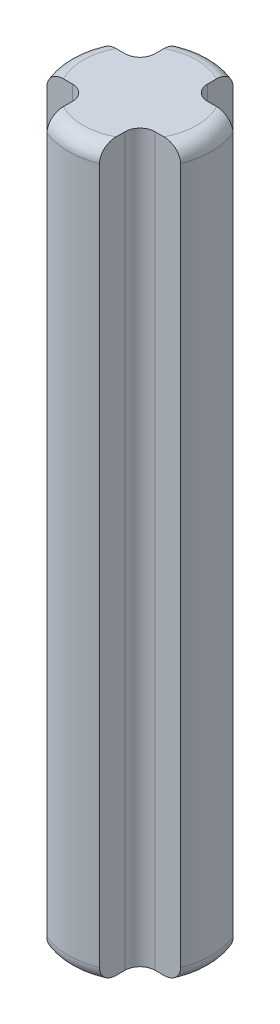
from build123d import *

# Parameters (mm, degrees)
SKETCH1_W          = 2.39
SKETCH1_H          = 24.195
CUT_EXTRUDE1_DEPTH = 25.195
CUT_EXTRUDE2_DEPTH = 25.195
CUT_EXTRUDE3_DEPTH = 25.195
CUT_EXTRUDE4_DEPTH = 25.195
FILLET1_R          = 0.5


with BuildPart() as part:
    # Sketch1 → Revolve1 (revolve)
    with BuildSketch(Plane(origin=(0, 0, 0), x_dir=(-1, 0, 0), z_dir=(0, 0, -1))):
        with Locations((-1.195, 12.0975)):
            Rectangle(SKETCH1_W, SKETCH1_H)
    revolve(axis=Axis((0, 0, 0), (0, 1, 0)))

    # Sketch2 → Cut-Extrude1 (cut, through all)
    with BuildSketch(Plane.XZ):
        with BuildLine():
            Line((0.875, 2.22406722), (0.875, 0.875))
            Line((0.875, 0.875), (2.22406722, 0.875))
            ThreePointArc((2.22406722, 0.875), (1.689985207, 1.689985207), (0.875, 2.22406722))
        make_face()
    extrude(amount=-CUT_EXTRUDE1_DEPTH, mode=Mode.SUBTRACT)

    # Sketch3 → Cut-Extrude2 (cut, through all)
    with BuildSketch(Plane.XZ):
        with BuildLine():
            Line((2.22406722, -0.875), (0.875, -0.875))
            Line((0.875, -0.875), (0.875, -2.22406722))
            ThreePointArc((0.875, -2.22406722), (1.689985207, -1.689985207), (2.22406722, -0.875))
        make_face()
    extrude(amount=-CUT_EXTRUDE2_DEPTH, mode=Mode.SUBTRACT)

    # Sketch4 → Cut-Extrude3 (cut, through all)
    with BuildSketch(Plane.XZ):
        with BuildLine():
            Line((-0.875, -2.22406722), (-0.875, -0.875))
            Line((-0.875, -0.875), (-2.22406722, -0.875))
            ThreePointArc((-2.22406722, -0.875), (-1.689985207, -1.689985207), (-0.875, -2.22406722))
        make_face()
    extrude(amount=-CUT_EXTRUDE3_DEPTH, mode=Mode.SUBTRACT)

    # Sketch5 → Cut-Extrude4 (cut, through all)
    with BuildSketch(Plane.XZ):
        with BuildLine():
            Line((-2.22406722, 0.875), (-0.875, 0.875))
            Line((-0.875, 0.875), (-0.875, 2.22406722))
            ThreePointArc((-0.875, 2.22406722), (-1.689985207, 1.689985207), (-2.22406722, 0.875))
        make_face()
    extrude(amount=-CUT_EXTRUDE4_DEPTH, mode=Mode.SUBTRACT)

    # Fillet1
    fillet1_edges = [part.edges().sort_by_distance(p)[0] for p in [
        (2.39, 0, 0),
        (0.875, 12.0975, 0.875),
        (0, 24.195, -2.39),
        (0, 0, -2.39),
        (0.875, 12.0975, -0.875),
        (-2.39, 24.195, 0),
        (-2.39, 0, 0),
        (-0.875, 12.0975, -0.875),
        (0, 24.195, 2.39),
        (0, 0, 2.39),
        (-0.875, 12.0975, 0.875),
        (2.39, 24.195, 0),
    ]]
    fillet(fillet1_edges, radius=FILLET1_R)


solid = part.part
